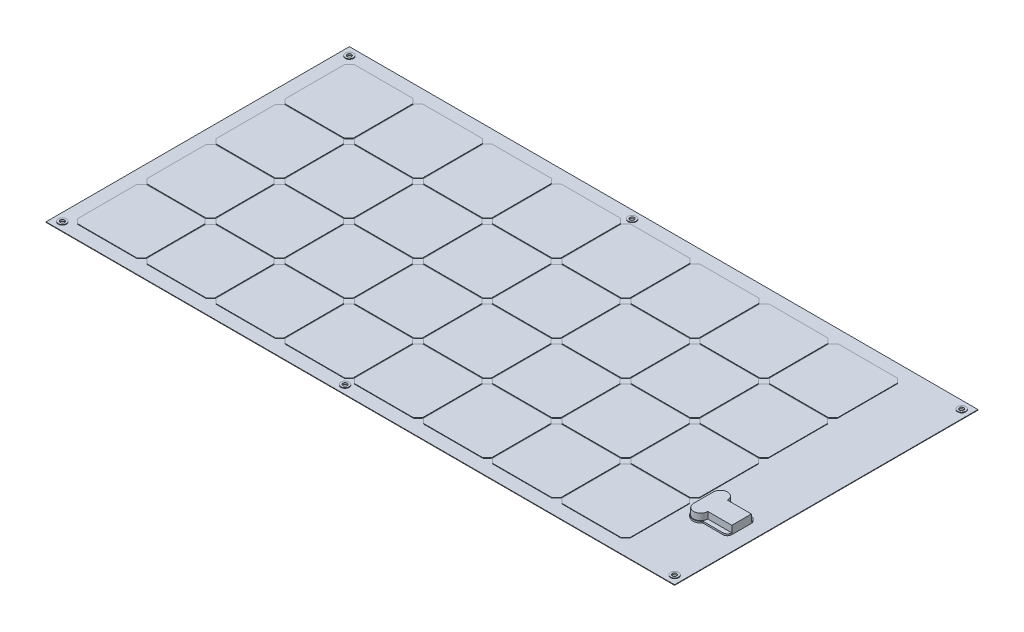
from build123d import *

# Parameters (mm, degrees)
SKETCH1_W                = 1154
SKETCH1_H                = 557
BOSS_EXTRUDE1_DEPTH      = 1
SKETCH2_R                = 4
CUT_EXTRUDE1_DEPTH       = 3
BOSS_EXTRUDE2_DEPTH      = 1
SKETCH4_R                = 7.5
SKETCH4_R_2              = 4
BOSS_EXTRUDE3_DEPTH      = 1
BOSS_EXTRUDE3_DEPTH_BACK = 2
BOSS_EXTRUDE4_DEPTH      = 3
BOSS_EXTRUDE5_DEPTH      = 12


with BuildPart() as part:
    # Sketch1 → Boss-Extrude1 (new body)
    with BuildSketch(Plane(origin=(0, 0, 0), x_dir=(1, 0, 0), z_dir=(0, 1, 0))):
        Rectangle(SKETCH1_W, SKETCH1_H)
    extrude(amount=BOSS_EXTRUDE1_DEPTH)

    # Sketch2 → Cut-Extrude1 (cut)
    with BuildSketch(Plane(origin=(0, 1, 0), x_dir=(1, 0, 0), z_dir=(0, 1, 0))):
        with Locations((-562, -263.5)):
            Circle(SKETCH2_R)
        with Locations((-43, -263.5)):
            Circle(SKETCH2_R)
        with Locations((562, -263.5)):
            Circle(SKETCH2_R)
        with Locations((562, 263.5)):
            Circle(SKETCH2_R)
        with Locations((-43, 263.5)):
            Circle(SKETCH2_R)
        with Locations((-562, 263.5)):
            Circle(SKETCH2_R)
    extrude(amount=-CUT_EXTRUDE1_DEPTH, mode=Mode.SUBTRACT)

    # Sketch3 → Boss-Extrude2 (add)
    with BuildSketch(Plane(origin=(0, 1, 0), x_dir=(1, 0, 0), z_dir=(0, 1, 0))):
        Polygon((-552, -136.5), (-544, -128.5), (-435, -128.5), (-427, -136.5), (-427, -245.5), (-435, -253.5), (-544, -253.5), (-552, -245.5), align=None)
        Polygon((-552, -9.5), (-544, -1.5), (-435, -1.5), (-427, -9.5), (-427, -118.5), (-435, -126.5), (-544, -126.5), (-552, -118.5), align=None)
        Polygon((-552, 117.5), (-544, 125.5), (-435, 125.5), (-427, 117.5), (-427, 8.5), (-435, 0.5), (-544, 0.5), (-552, 8.5), align=None)
        Polygon((-552, 245.5), (-544, 253.5), (-435, 253.5), (-427, 245.5), (-427, 135.5), (-435, 127.5), (-544, 127.5), (-552, 135.5), align=None)
        Polygon((-300, 135.5), (-308, 127.5), (-417, 127.5), (-425, 135.5), (-425, 245.5), (-417, 253.5), (-308, 253.5), (-300, 245.5), align=None)
        Polygon((-300, 8.5), (-308, 0.5), (-417, 0.5), (-425, 8.5), (-425, 117.5), (-417, 125.5), (-308, 125.5), (-300, 117.5), align=None)
        Polygon((-300, -118.5), (-308, -126.5), (-417, -126.5), (-425, -118.5), (-425, -9.5), (-417, -1.5), (-308, -1.5), (-300, -9.5), align=None)
        Polygon((-300, -245.5), (-308, -253.5), (-417, -253.5), (-425, -245.5), (-425, -136.5), (-417, -128.5), (-308, -128.5), (-300, -136.5), align=None)
        Polygon((-298, -136.5), (-290, -128.5), (-181, -128.5), (-173, -136.5), (-173, -245.5), (-181, -253.5), (-290, -253.5), (-298, -245.5), align=None)
        Polygon((-298, -9.5), (-290, -1.5), (-181, -1.5), (-173, -9.5), (-173, -118.5), (-181, -126.5), (-290, -126.5), (-298, -118.5), align=None)
        Polygon((-298, 117.5), (-290, 125.5), (-181, 125.5), (-173, 117.5), (-173, 8.5), (-181, 0.5), (-290, 0.5), (-298, 8.5), align=None)
        Polygon((-298, 245.5), (-290, 253.5), (-181, 253.5), (-173, 245.5), (-173, 135.5), (-181, 127.5), (-290, 127.5), (-298, 135.5), align=None)
        Polygon((-46, 135.5), (-54, 127.5), (-163, 127.5), (-171, 135.5), (-171, 245.5), (-163, 253.5), (-54, 253.5), (-46, 245.5), align=None)
        Polygon((-46, 8.5), (-54, 0.5), (-163, 0.5), (-171, 8.5), (-171, 117.5), (-163, 125.5), (-54, 125.5), (-46, 117.5), align=None)
        Polygon((-46, -118.5), (-54, -126.5), (-163, -126.5), (-171, -118.5), (-171, -9.5), (-163, -1.5), (-54, -1.5), (-46, -9.5), align=None)
        Polygon((-46, -245.5), (-54, -253.5), (-163, -253.5), (-171, -245.5), (-171, -136.5), (-163, -128.5), (-54, -128.5), (-46, -136.5), align=None)
        Polygon((-44, -136.5), (-36, -128.5), (73, -128.5), (81, -136.5), (81, -245.5), (73, -253.5), (-36, -253.5), (-44, -245.5), align=None)
        Polygon((-44, -9.5), (-36, -1.5), (73, -1.5), (81, -9.5), (81, -118.5), (73, -126.5), (-36, -126.5), (-44, -118.5), align=None)
        Polygon((-44, 117.5), (-36, 125.5), (73, 125.5), (81, 117.5), (81, 8.5), (73, 0.5), (-36, 0.5), (-44, 8.5), align=None)
        Polygon((-44, 245.5), (-36, 253.5), (73, 253.5), (81, 245.5), (81, 135.5), (73, 127.5), (-36, 127.5), (-44, 135.5), align=None)
        Polygon((208, 135.5), (200, 127.5), (91, 127.5), (83, 135.5), (83, 245.5), (91, 253.5), (200, 253.5), (208, 245.5), align=None)
        Polygon((208, 8.5), (200, 0.5), (91, 0.5), (83, 8.5), (83, 117.5), (91, 125.5), (200, 125.5), (208, 117.5), align=None)
        Polygon((208, -118.5), (200, -126.5), (91, -126.5), (83, -118.5), (83, -9.5), (91, -1.5), (200, -1.5), (208, -9.5), align=None)
        Polygon((208, -245.5), (200, -253.5), (91, -253.5), (83, -245.5), (83, -136.5), (91, -128.5), (200, -128.5), (208, -136.5), align=None)
        Polygon((210, -136.5), (218, -128.5), (327, -128.5), (335, -136.5), (335, -245.5), (327, -253.5), (218, -253.5), (210, -245.5), align=None)
        Polygon((210, -9.5), (218, -1.5), (327, -1.5), (335, -9.5), (335, -118.5), (327, -126.5), (218, -126.5), (210, -118.5), align=None)
        Polygon((210, 117.5), (218, 125.5), (327, 125.5), (335, 117.5), (335, 8.5), (327, 0.5), (218, 0.5), (210, 8.5), align=None)
        Polygon((210, 245.5), (218, 253.5), (327, 253.5), (335, 245.5), (335, 135.5), (327, 127.5), (218, 127.5), (210, 135.5), align=None)
        Polygon((462, 135.5), (454, 127.5), (345, 127.5), (337, 135.5), (337, 245.5), (345, 253.5), (454, 253.5), (462, 245.5), align=None)
        Polygon((462, 8.5), (454, 0.5), (345, 0.5), (337, 8.5), (337, 117.5), (345, 125.5), (454, 125.5), (462, 117.5), align=None)
        Polygon((462, -118.5), (454, -126.5), (345, -126.5), (337, -118.5), (337, -9.5), (345, -1.5), (454, -1.5), (462, -9.5), align=None)
        Polygon((462, -245.5), (454, -253.5), (345, -253.5), (337, -245.5), (337, -136.5), (345, -128.5), (454, -128.5), (462, -136.5), align=None)
    extrude(amount=BOSS_EXTRUDE2_DEPTH)

    # Sketch4 → Boss-Extrude3 (add, two sides)
    with BuildSketch(Plane(origin=(0, 1, 0), x_dir=(1, 0, 0), z_dir=(0, 1, 0))) as boss_extrude3_sk:
        with Locations((-562, -263.5)):
            Circle(SKETCH4_R)
        with Locations((-562, -263.5)):
            Circle(SKETCH4_R_2, mode=Mode.SUBTRACT)
        with Locations((-43, -263.5)):
            Circle(SKETCH4_R)
        with Locations((-43, -263.5)):
            Circle(SKETCH4_R_2, mode=Mode.SUBTRACT)
        with Locations((562, -263.5)):
            Circle(SKETCH4_R)
        with Locations((562, -263.5)):
            Circle(SKETCH4_R_2, mode=Mode.SUBTRACT)
        with Locations((562, 263.5)):
            Circle(SKETCH4_R)
        with Locations((562, 263.5)):
            Circle(SKETCH4_R_2, mode=Mode.SUBTRACT)
        with Locations((-43, 263.5)):
            Circle(SKETCH4_R)
        with Locations((-43, 263.5)):
            Circle(SKETCH4_R_2, mode=Mode.SUBTRACT)
        with Locations((-562, 263.5)):
            Circle(SKETCH4_R)
        with Locations((-562, 263.5)):
            Circle(SKETCH4_R_2, mode=Mode.SUBTRACT)
    extrude(amount=BOSS_EXTRUDE3_DEPTH)
    extrude(boss_extrude3_sk.sketch, amount=-BOSS_EXTRUDE3_DEPTH_BACK)

    # Sketch5 → Boss-Extrude4 (add)
    with BuildSketch(Plane(origin=(0, 1, 0), x_dir=(1, 0, 0), z_dir=(0, 1, 0))):
        with BuildLine():
            Line((478.006496587, -111.467195071), (478.006496587, -145.532804929))
            ThreePointArc((478.006496587, -145.532804929), (488.282515568, -159.76951815), (505.031030364, -154.5))
            Line((505.031030364, -154.5), (542, -154.5))
            ThreePointArc((542, -154.5), (547.656854249, -152.156854249), (550, -146.5))
            Line((550, -146.5), (550, -110.5))
            ThreePointArc((550, -110.5), (547.656854249, -104.843145751), (542, -102.5))
            Line((542, -102.5), (505.031030364, -102.5))
            ThreePointArc((505.031030364, -102.5), (488.282515568, -97.23048185), (478.006496587, -111.467195071))
        make_face()
    extrude(amount=BOSS_EXTRUDE4_DEPTH)

    # Sketch6 → Boss-Extrude5 (add)
    with BuildSketch(Plane(origin=(0, 4, 0), x_dir=(1, 0, 0), z_dir=(0, 1, 0))):
        with BuildLine():
            Line((506, -110.5), (550, -110.5))
            Line((550, -110.5), (550, -146.5))
            Line((550, -146.5), (506, -146.5))
            ThreePointArc((506, -146.5), (493, -159.5), (480, -146.5))
            Line((480, -146.5), (480, -110.5))
            ThreePointArc((480, -110.5), (493, -97.5), (506, -110.5))
        make_face()
    extrude(amount=BOSS_EXTRUDE5_DEPTH)


solid = part.part
